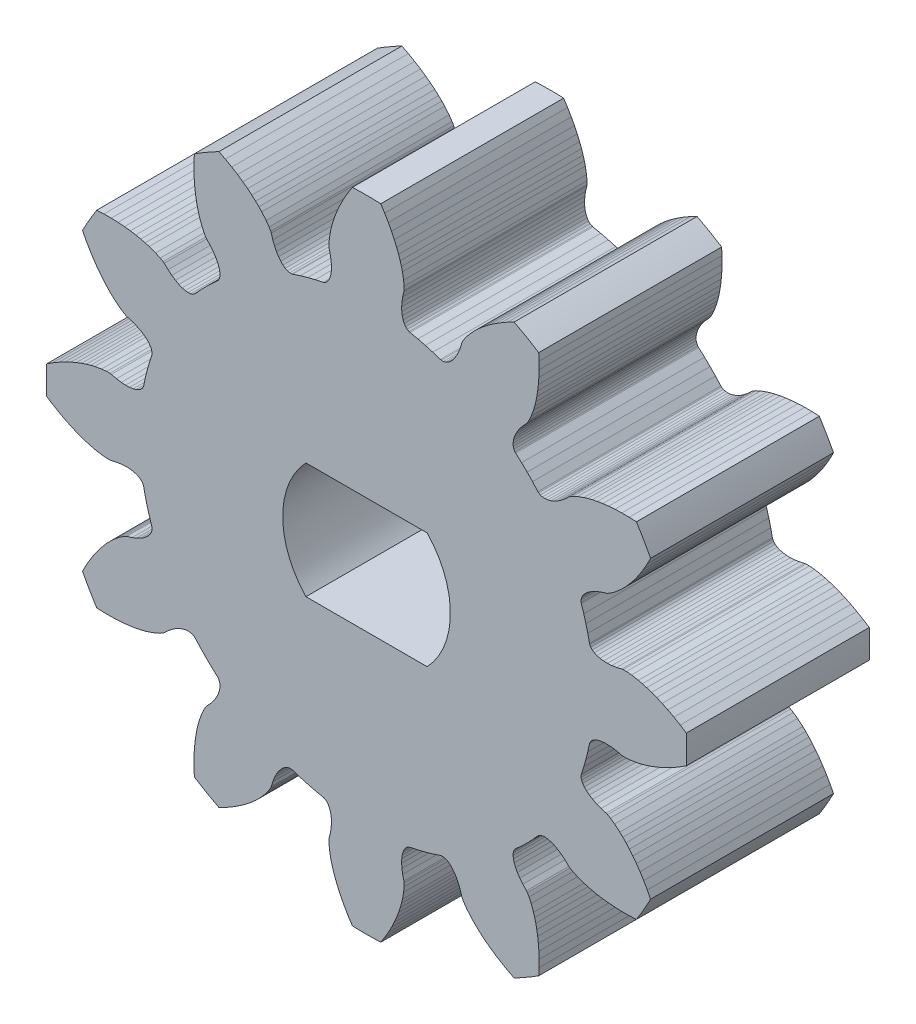
from build123d import *

# Parameters (mm, degrees)
BOSS_EXTRUDE1_DEPTH     = 3
CUT_EXTRUDE1_DEPTH      = 1
CUT_EXTRUDE1_DEPTH_BACK = 7


with BuildPart() as part:
    # Model → Boss-Extrude1 (new body, symmetric)
    with BuildSketch(Plane.XY):
        with BuildLine():
            Line((9.2081638, 4.6306746), (9.0896937, 4.4223953))
            Line((9.0896937, 4.4223953), (8.9704789, 4.2318475))
            Line((8.9704789, 4.2318475), (8.8518121, 4.0587667))
            Line((8.8518121, 4.0587667), (8.7350822, 3.9029142))
            Line((8.7350822, 3.9029142), (8.6215838, 3.7639019))
            Line((8.6215838, 3.7639019), (8.510786, 3.6392686))
            Line((8.510786, 3.6392686), (8.4071579, 3.5321165))
            Line((8.4071579, 3.5321165), (8.3089199, 3.4386561))
            Line((8.3089199, 3.4386561), (8.1362464, 3.2934574))
            Line((8.1362464, 3.2934574), (7.9993186, 3.196525))
            Line((7.9993186, 3.196525), (7.9059174, 3.1414234))
            Line((7.9059174, 3.1414234), (7.8611648, 3.1240278))
            Line((7.8611648, 3.1240278), (7.69584, 3.074501))
            Line((7.69584, 3.074501), (7.5485028, 3.0172672))
            Line((7.5485028, 3.0172672), (7.4194762, 2.9537483))
            Line((7.4194762, 2.9537483), (7.3090078, 2.8853773))
            Line((7.3090078, 2.8853773), (7.2172479, 2.8136024))
            Line((7.2172479, 2.8136024), (7.1442598, 2.7398486))
            Line((7.1442598, 2.7398486), (7.0900211, 2.6655903))
            Line((7.0900211, 2.6655903), (7.0544136, 2.5922348))
            Line((7.0544136, 2.5922348), (7.037248, 2.5212224))
            Line((7.037248, 2.5212224), (7.0382291, 2.4539645))
            Line((7.0382291, 2.4539645), (7.0454224, 2.4221731))
            Line((7.0454224, 2.4221731), (7.126272, 2.1723665))
            Line((7.126272, 2.1723665), (7.1961474, 1.9282019))
            Line((7.1961474, 1.9282019), (7.2577158, 1.6818114))
            Line((7.2577158, 1.6818114), (7.3126013, 1.4250478))
            Line((7.3126013, 1.4250478), (7.3222675, 1.3939189))
            Line((7.3222675, 1.3939189), (7.3550468, 1.3351814))
            Line((7.3550468, 1.3351814), (7.4054188, 1.2822656))
            Line((7.4054188, 1.2822656), (7.4729335, 1.2365416))
            Line((7.4729335, 1.2365416), (7.5570347, 1.1993514))
            Line((7.5570347, 1.1993514), (7.6571212, 1.1719728))
            Line((7.6571212, 1.1719728), (7.7724751, 1.1556939))
            Line((7.7724751, 1.1556939), (7.902329, 1.1517171))
            Line((7.902329, 1.1517171), (8.0458288, 1.1612214))
            Line((8.0458288, 1.1612214), (8.2020434, 1.185324))
            Line((8.2020434, 1.185324), (8.3699823, 1.2250949))
            Line((8.3699823, 1.2250949), (8.417437, 1.2324062))
            Line((8.417437, 1.2324062), (8.5258756, 1.2313875))
            Line((8.5258756, 1.2313875), (8.6929247, 1.2159055))
            Line((8.6929247, 1.2159055), (8.9150637, 1.1764964))
            Line((8.9150637, 1.1764964), (9.0468706, 1.1446763))
            Line((9.0468706, 1.1446763), (9.1901912, 1.103694))
            Line((9.1901912, 1.103694), (9.3484616, 1.0511572))
            Line((9.3484616, 1.0511572), (9.5162602, 0.9875182))
            Line((9.5162602, 0.9875182), (9.6952775, 0.910911))
            Line((9.6952775, 0.910911), (9.8845864, 0.820352))
            Line((9.8845864, 0.820352), (10.0831033, 0.7149402))
            Line((10.0831033, 0.7149402), (10.2898411, 0.5938001))
            Line((10.2898411, 0.5938001), (10.489639, 0.465274))
            ThreePointArc((10.489639, 0.465274), (10.499952632, 0), (10.489639, -0.465274))
            Line((10.489639, -0.465274), (10.2898411, -0.5938001))
            Line((10.2898411, -0.5938001), (10.0831033, -0.7149402))
            Line((10.0831033, -0.7149402), (9.8845864, -0.820352))
            Line((9.8845864, -0.820352), (9.6952775, -0.910911))
            Line((9.6952775, -0.910911), (9.5162602, -0.9875182))
            Line((9.5162602, -0.9875182), (9.3484616, -1.0511572))
            Line((9.3484616, -1.0511572), (9.1901912, -1.103694))
            Line((9.1901912, -1.103694), (9.0468706, -1.1446763))
            Line((9.0468706, -1.1446763), (8.9150637, -1.1764964))
            Line((8.9150637, -1.1764964), (8.6929247, -1.2159055))
            Line((8.6929247, -1.2159055), (8.5258756, -1.2313875))
            Line((8.5258756, -1.2313875), (8.417437, -1.2324062))
            Line((8.417437, -1.2324062), (8.3699823, -1.2250949))
            Line((8.3699823, -1.2250949), (8.2020434, -1.185324))
            Line((8.2020434, -1.185324), (8.0458288, -1.1612214))
            Line((8.0458288, -1.1612214), (7.902329, -1.1517171))
            Line((7.902329, -1.1517171), (7.7724751, -1.1556939))
            Line((7.7724751, -1.1556939), (7.6571212, -1.1719728))
            Line((7.6571212, -1.1719728), (7.5570347, -1.1993514))
            Line((7.5570347, -1.1993514), (7.4729335, -1.2365416))
            Line((7.4729335, -1.2365416), (7.4054188, -1.2822656))
            Line((7.4054188, -1.2822656), (7.3550468, -1.3351814))
            Line((7.3550468, -1.3351814), (7.3222675, -1.3939189))
            Line((7.3222675, -1.3939189), (7.3126013, -1.4250478))
            Line((7.3126013, -1.4250478), (7.2577158, -1.6818114))
            Line((7.2577158, -1.6818114), (7.1961474, -1.9282019))
            Line((7.1961474, -1.9282019), (7.126272, -2.1723665))
            Line((7.126272, -2.1723665), (7.0454224, -2.4221731))
            Line((7.0454224, -2.4221731), (7.0382291, -2.4539645))
            Line((7.0382291, -2.4539645), (7.037248, -2.5212224))
            Line((7.037248, -2.5212224), (7.0544136, -2.5922348))
            Line((7.0544136, -2.5922348), (7.0900211, -2.6655903))
            Line((7.0900211, -2.6655903), (7.1442598, -2.7398486))
            Line((7.1442598, -2.7398486), (7.2172479, -2.8136024))
            Line((7.2172479, -2.8136024), (7.3090078, -2.8853773))
            Line((7.3090078, -2.8853773), (7.4194762, -2.9537483))
            Line((7.4194762, -2.9537483), (7.5485028, -3.0172672))
            Line((7.5485028, -3.0172672), (7.69584, -3.074501))
            Line((7.69584, -3.074501), (7.8611648, -3.1240278))
            Line((7.8611648, -3.1240278), (7.9059174, -3.1414234))
            Line((7.9059174, -3.1414234), (7.9993186, -3.196525))
            Line((7.9993186, -3.196525), (8.1362464, -3.2934574))
            Line((8.1362464, -3.2934574), (8.3089199, -3.4386561))
            Line((8.3089199, -3.4386561), (8.4071579, -3.5321165))
            Line((8.4071579, -3.5321165), (8.510786, -3.6392686))
            Line((8.510786, -3.6392686), (8.6215838, -3.7639019))
            Line((8.6215838, -3.7639019), (8.7350822, -3.9029142))
            Line((8.7350822, -3.9029142), (8.8518121, -4.0587667))
            Line((8.8518121, -4.0587667), (8.9704789, -4.2318475))
            Line((8.9704789, -4.2318475), (9.0896937, -4.4223953))
            Line((9.0896937, -4.4223953), (9.2081638, -4.6306746))
            Line((9.2081638, -4.6306746), (9.3169308, -4.8418803))
            ThreePointArc((9.3169308, -4.8418803), (9.093225669, -5.249976266), (8.8516568, -5.6477586))
            Line((8.8516568, -5.6477586), (8.6143637, -5.6591665))
            Line((8.6143637, -5.6591665), (8.3747535, -5.660708))
            Line((8.3747535, -5.660708), (8.1501269, -5.6527389))
            Line((8.1501269, -5.6527389), (7.9409011, -5.6365108))
            Line((7.9409011, -5.6365108), (7.7475639, -5.613346))
            Line((7.7475639, -5.613346), (7.5704266, -5.5845597))
            Line((7.5704266, -5.5845597), (7.407092, -5.5509226))
            Line((7.407092, -5.5509226), (7.2624816, -5.5147541))
            Line((7.2624816, -5.5147541), (7.1324235, -5.4764077))
            Line((7.1324235, -5.4764077), (6.9203409, -5.3994674))
            Line((6.9203409, -5.3994674), (6.7679311, -5.3293507))
            Line((6.7679311, -5.3293507), (6.6735112, -5.2760136))
            Line((6.6735112, -5.2760136), (6.6360699, -5.2459545))
            Line((6.6360699, -5.2459545), (6.510516, -5.1275424))
            Line((6.510516, -5.1275424), (6.3872814, -5.0285616))
            Line((6.3872814, -5.0285616), (6.2677592, -4.9485807))
            Line((6.2677592, -4.9485807), (6.1533139, -4.8870978))
            Line((6.1533139, -4.8870978), (6.0452751, -4.8435188))
            Line((6.0452751, -4.8435188), (5.9449083, -4.8171862))
            Line((5.9449083, -4.8171862), (5.8534794, -4.8073432))
            Line((5.8534794, -4.8073432), (5.772148, -4.8131839))
            Line((5.772148, -4.8131839), (5.7020667, -4.8338244))
            Line((5.7020667, -4.8338244), (5.6443102, -4.8683029))
            Line((5.6443102, -4.8683029), (5.6203746, -4.8904283))
            Line((5.6203746, -4.8904283), (5.4444606, -5.0853493))
            Line((5.4444606, -5.0853493), (5.2679455, -5.2679455))
            Line((5.2679455, -5.2679455), (5.0853493, -5.4444606))
            Line((5.0853493, -5.4444606), (4.8904283, -5.6203746))
            Line((4.8904283, -5.6203746), (4.8683029, -5.6443102))
            Line((4.8683029, -5.6443102), (4.8338244, -5.7020667))
            Line((4.8338244, -5.7020667), (4.8131839, -5.772148))
            Line((4.8131839, -5.772148), (4.8073432, -5.8534794))
            Line((4.8073432, -5.8534794), (4.8171862, -5.9449083))
            Line((4.8171862, -5.9449083), (4.8435188, -6.0452751))
            Line((4.8435188, -6.0452751), (4.8870978, -6.1533139))
            Line((4.8870978, -6.1533139), (4.9485807, -6.2677592))
            Line((4.9485807, -6.2677592), (5.0285616, -6.3872814))
            Line((5.0285616, -6.3872814), (5.1275424, -6.510516))
            Line((5.1275424, -6.510516), (5.2459545, -6.6360699))
            Line((5.2459545, -6.6360699), (5.2760136, -6.6735112))
            Line((5.2760136, -6.6735112), (5.3293507, -6.7679311))
            Line((5.3293507, -6.7679311), (5.3994674, -6.9203409))
            Line((5.3994674, -6.9203409), (5.4764077, -7.1324235))
            Line((5.4764077, -7.1324235), (5.5147541, -7.2624816))
            Line((5.5147541, -7.2624816), (5.5509226, -7.407092))
            Line((5.5509226, -7.407092), (5.5845597, -7.5704266))
            Line((5.5845597, -7.5704266), (5.613346, -7.7475639))
            Line((5.613346, -7.7475639), (5.6365108, -7.9409011))
            Line((5.6365108, -7.9409011), (5.6527389, -8.1501269))
            Line((5.6527389, -8.1501269), (5.660708, -8.3747535))
            Line((5.660708, -8.3747535), (5.6591665, -8.6143637))
            Line((5.6591665, -8.6143637), (5.6477586, -8.8516568))
            ThreePointArc((5.6477586, -8.8516568), (5.249976266, -9.093225669), (4.8418803, -9.3169308))
            Line((4.8418803, -9.3169308), (4.6306746, -9.2081638))
            Line((4.6306746, -9.2081638), (4.4223953, -9.0896937))
            Line((4.4223953, -9.0896937), (4.2318475, -8.9704789))
            Line((4.2318475, -8.9704789), (4.0587667, -8.8518121))
            Line((4.0587667, -8.8518121), (3.9029142, -8.7350822))
            Line((3.9029142, -8.7350822), (3.7639019, -8.6215838))
            Line((3.7639019, -8.6215838), (3.6392686, -8.510786))
            Line((3.6392686, -8.510786), (3.5321165, -8.4071579))
            Line((3.5321165, -8.4071579), (3.4386561, -8.3089199))
            Line((3.4386561, -8.3089199), (3.2934574, -8.1362464))
            Line((3.2934574, -8.1362464), (3.196525, -7.9993186))
            Line((3.196525, -7.9993186), (3.1414234, -7.9059174))
            Line((3.1414234, -7.9059174), (3.1240278, -7.8611648))
            Line((3.1240278, -7.8611648), (3.074501, -7.69584))
            Line((3.074501, -7.69584), (3.0172672, -7.5485028))
            Line((3.0172672, -7.5485028), (2.9537483, -7.4194762))
            Line((2.9537483, -7.4194762), (2.8853773, -7.3090078))
            Line((2.8853773, -7.3090078), (2.8136024, -7.2172479))
            Line((2.8136024, -7.2172479), (2.7398486, -7.1442598))
            Line((2.7398486, -7.1442598), (2.6655903, -7.0900211))
            Line((2.6655903, -7.0900211), (2.5922348, -7.0544136))
            Line((2.5922348, -7.0544136), (2.5212224, -7.037248))
            Line((2.5212224, -7.037248), (2.4539645, -7.0382291))
            Line((2.4539645, -7.0382291), (2.4221731, -7.0454224))
            Line((2.4221731, -7.0454224), (2.1723665, -7.126272))
            Line((2.1723665, -7.126272), (1.9282019, -7.1961474))
            Line((1.9282019, -7.1961474), (1.6818114, -7.2577158))
            Line((1.6818114, -7.2577158), (1.4250478, -7.3126013))
            Line((1.4250478, -7.3126013), (1.3939189, -7.3222675))
            Line((1.3939189, -7.3222675), (1.3351814, -7.3550468))
            Line((1.3351814, -7.3550468), (1.2822656, -7.4054188))
            Line((1.2822656, -7.4054188), (1.2365416, -7.4729335))
            Line((1.2365416, -7.4729335), (1.1993514, -7.5570347))
            Line((1.1993514, -7.5570347), (1.1719728, -7.6571212))
            Line((1.1719728, -7.6571212), (1.1556939, -7.7724751))
            Line((1.1556939, -7.7724751), (1.1517171, -7.902329))
            Line((1.1517171, -7.902329), (1.1612214, -8.0458288))
            Line((1.1612214, -8.0458288), (1.185324, -8.2020434))
            Line((1.185324, -8.2020434), (1.2250949, -8.3699823))
            Line((1.2250949, -8.3699823), (1.2324062, -8.417437))
            Line((1.2324062, -8.417437), (1.2313875, -8.5258756))
            Line((1.2313875, -8.5258756), (1.2159055, -8.6929247))
            Line((1.2159055, -8.6929247), (1.1764964, -8.9150637))
            Line((1.1764964, -8.9150637), (1.1446763, -9.0468706))
            Line((1.1446763, -9.0468706), (1.103694, -9.1901912))
            Line((1.103694, -9.1901912), (1.0511572, -9.3484616))
            Line((1.0511572, -9.3484616), (0.9875182, -9.5162602))
            Line((0.9875182, -9.5162602), (0.910911, -9.6952775))
            Line((0.910911, -9.6952775), (0.820352, -9.8845864))
            Line((0.820352, -9.8845864), (0.7149402, -10.0831033))
            Line((0.7149402, -10.0831033), (0.5938001, -10.2898411))
            Line((0.5938001, -10.2898411), (0.465274, -10.489639))
            ThreePointArc((0.465274, -10.489639), (0, -10.499952632), (-0.465274, -10.489639))
            Line((-0.465274, -10.489639), (-0.5938001, -10.2898411))
            Line((-0.5938001, -10.2898411), (-0.7149402, -10.0831033))
            Line((-0.7149402, -10.0831033), (-0.820352, -9.8845864))
            Line((-0.820352, -9.8845864), (-0.910911, -9.6952775))
            Line((-0.910911, -9.6952775), (-0.9875182, -9.5162602))
            Line((-0.9875182, -9.5162602), (-1.0511572, -9.3484616))
            Line((-1.0511572, -9.3484616), (-1.103694, -9.1901912))
            Line((-1.103694, -9.1901912), (-1.1446763, -9.0468706))
            Line((-1.1446763, -9.0468706), (-1.1764964, -8.9150637))
            Line((-1.1764964, -8.9150637), (-1.2159055, -8.6929247))
            Line((-1.2159055, -8.6929247), (-1.2313875, -8.5258756))
            Line((-1.2313875, -8.5258756), (-1.2324062, -8.417437))
            Line((-1.2324062, -8.417437), (-1.2250949, -8.3699823))
            Line((-1.2250949, -8.3699823), (-1.185324, -8.2020434))
            Line((-1.185324, -8.2020434), (-1.1612214, -8.0458288))
            Line((-1.1612214, -8.0458288), (-1.1517171, -7.902329))
            Line((-1.1517171, -7.902329), (-1.1556939, -7.7724751))
            Line((-1.1556939, -7.7724751), (-1.1719728, -7.6571212))
            Line((-1.1719728, -7.6571212), (-1.1993514, -7.5570347))
            Line((-1.1993514, -7.5570347), (-1.2365416, -7.4729335))
            Line((-1.2365416, -7.4729335), (-1.2822656, -7.4054188))
            Line((-1.2822656, -7.4054188), (-1.3351814, -7.3550468))
            Line((-1.3351814, -7.3550468), (-1.3939189, -7.3222675))
            Line((-1.3939189, -7.3222675), (-1.4250478, -7.3126013))
            Line((-1.4250478, -7.3126013), (-1.6818114, -7.2577158))
            Line((-1.6818114, -7.2577158), (-1.9282019, -7.1961474))
            Line((-1.9282019, -7.1961474), (-2.1723665, -7.126272))
            Line((-2.1723665, -7.126272), (-2.4221731, -7.0454224))
            Line((-2.4221731, -7.0454224), (-2.4539645, -7.0382291))
            Line((-2.4539645, -7.0382291), (-2.5212224, -7.037248))
            Line((-2.5212224, -7.037248), (-2.5922348, -7.0544136))
            Line((-2.5922348, -7.0544136), (-2.6655903, -7.0900211))
            Line((-2.6655903, -7.0900211), (-2.7398486, -7.1442598))
            Line((-2.7398486, -7.1442598), (-2.8136024, -7.2172479))
            Line((-2.8136024, -7.2172479), (-2.8853773, -7.3090078))
            Line((-2.8853773, -7.3090078), (-2.9537483, -7.4194762))
            Line((-2.9537483, -7.4194762), (-3.0172672, -7.5485028))
            Line((-3.0172672, -7.5485028), (-3.074501, -7.69584))
            Line((-3.074501, -7.69584), (-3.1240278, -7.8611648))
            Line((-3.1240278, -7.8611648), (-3.1414234, -7.9059174))
            Line((-3.1414234, -7.9059174), (-3.196525, -7.9993186))
            Line((-3.196525, -7.9993186), (-3.2934574, -8.1362464))
            Line((-3.2934574, -8.1362464), (-3.4386561, -8.3089199))
            Line((-3.4386561, -8.3089199), (-3.5321165, -8.4071579))
            Line((-3.5321165, -8.4071579), (-3.6392686, -8.510786))
            Line((-3.6392686, -8.510786), (-3.7639019, -8.6215838))
            Line((-3.7639019, -8.6215838), (-3.9029142, -8.7350822))
            Line((-3.9029142, -8.7350822), (-4.0587667, -8.8518121))
            Line((-4.0587667, -8.8518121), (-4.2318475, -8.9704789))
            Line((-4.2318475, -8.9704789), (-4.4223953, -9.0896937))
            Line((-4.4223953, -9.0896937), (-4.6306746, -9.2081638))
            Line((-4.6306746, -9.2081638), (-4.8418803, -9.3169308))
            ThreePointArc((-4.8418803, -9.3169308), (-5.249976266, -9.093225669), (-5.6477586, -8.8516568))
            Line((-5.6477586, -8.8516568), (-5.6591665, -8.6143637))
            Line((-5.6591665, -8.6143637), (-5.660708, -8.3747535))
            Line((-5.660708, -8.3747535), (-5.6527389, -8.1501269))
            Line((-5.6527389, -8.1501269), (-5.6365108, -7.9409011))
            Line((-5.6365108, -7.9409011), (-5.613346, -7.7475639))
            Line((-5.613346, -7.7475639), (-5.5845597, -7.5704266))
            Line((-5.5845597, -7.5704266), (-5.5509226, -7.407092))
            Line((-5.5509226, -7.407092), (-5.5147541, -7.2624816))
            Line((-5.5147541, -7.2624816), (-5.4764077, -7.1324235))
            Line((-5.4764077, -7.1324235), (-5.3994674, -6.9203409))
            Line((-5.3994674, -6.9203409), (-5.3293507, -6.7679311))
            Line((-5.3293507, -6.7679311), (-5.2760136, -6.6735112))
            Line((-5.2760136, -6.6735112), (-5.2459545, -6.6360699))
            Line((-5.2459545, -6.6360699), (-5.1275424, -6.510516))
            Line((-5.1275424, -6.510516), (-5.0285616, -6.3872814))
            Line((-5.0285616, -6.3872814), (-4.9485807, -6.2677592))
            Line((-4.9485807, -6.2677592), (-4.8870978, -6.1533139))
            Line((-4.8870978, -6.1533139), (-4.8435188, -6.0452751))
            Line((-4.8435188, -6.0452751), (-4.8171862, -5.9449083))
            Line((-4.8171862, -5.9449083), (-4.8073432, -5.8534794))
            Line((-4.8073432, -5.8534794), (-4.8131839, -5.772148))
            Line((-4.8131839, -5.772148), (-4.8338244, -5.7020667))
            Line((-4.8338244, -5.7020667), (-4.8683029, -5.6443102))
            Line((-4.8683029, -5.6443102), (-4.8904283, -5.6203746))
            Line((-4.8904283, -5.6203746), (-5.0853493, -5.4444606))
            Line((-5.0853493, -5.4444606), (-5.2679455, -5.2679455))
            Line((-5.2679455, -5.2679455), (-5.4444606, -5.0853493))
            Line((-5.4444606, -5.0853493), (-5.6203746, -4.8904283))
            Line((-5.6203746, -4.8904283), (-5.6443102, -4.8683029))
            Line((-5.6443102, -4.8683029), (-5.7020667, -4.8338244))
            Line((-5.7020667, -4.8338244), (-5.772148, -4.8131839))
            Line((-5.772148, -4.8131839), (-5.8534794, -4.8073432))
            Line((-5.8534794, -4.8073432), (-5.9449083, -4.8171862))
            Line((-5.9449083, -4.8171862), (-6.0452751, -4.8435188))
            Line((-6.0452751, -4.8435188), (-6.1533139, -4.8870978))
            Line((-6.1533139, -4.8870978), (-6.2677592, -4.9485807))
            Line((-6.2677592, -4.9485807), (-6.3872814, -5.0285616))
            Line((-6.3872814, -5.0285616), (-6.510516, -5.1275424))
            Line((-6.510516, -5.1275424), (-6.6360699, -5.2459545))
            Line((-6.6360699, -5.2459545), (-6.6735112, -5.2760136))
            Line((-6.6735112, -5.2760136), (-6.7679311, -5.3293507))
            Line((-6.7679311, -5.3293507), (-6.9203409, -5.3994674))
            Line((-6.9203409, -5.3994674), (-7.1324235, -5.4764077))
            Line((-7.1324235, -5.4764077), (-7.2624816, -5.5147541))
            Line((-7.2624816, -5.5147541), (-7.407092, -5.5509226))
            Line((-7.407092, -5.5509226), (-7.5704266, -5.5845597))
            Line((-7.5704266, -5.5845597), (-7.7475639, -5.613346))
            Line((-7.7475639, -5.613346), (-7.9409011, -5.6365108))
            Line((-7.9409011, -5.6365108), (-8.1501269, -5.6527389))
            Line((-8.1501269, -5.6527389), (-8.3747535, -5.660708))
            Line((-8.3747535, -5.660708), (-8.6143637, -5.6591665))
            Line((-8.6143637, -5.6591665), (-8.8516568, -5.6477586))
            ThreePointArc((-8.8516568, -5.6477586), (-9.093225669, -5.249976266), (-9.3169308, -4.8418803))
            Line((-9.3169308, -4.8418803), (-9.2081638, -4.6306746))
            Line((-9.2081638, -4.6306746), (-9.0896937, -4.4223953))
            Line((-9.0896937, -4.4223953), (-8.9704789, -4.2318475))
            Line((-8.9704789, -4.2318475), (-8.8518121, -4.0587667))
            Line((-8.8518121, -4.0587667), (-8.7350822, -3.9029142))
            Line((-8.7350822, -3.9029142), (-8.6215838, -3.7639019))
            Line((-8.6215838, -3.7639019), (-8.510786, -3.6392686))
            Line((-8.510786, -3.6392686), (-8.4071579, -3.5321165))
            Line((-8.4071579, -3.5321165), (-8.3089199, -3.4386561))
            Line((-8.3089199, -3.4386561), (-8.1362464, -3.2934574))
            Line((-8.1362464, -3.2934574), (-7.9993186, -3.196525))
            Line((-7.9993186, -3.196525), (-7.9059174, -3.1414234))
            Line((-7.9059174, -3.1414234), (-7.8611648, -3.1240278))
            Line((-7.8611648, -3.1240278), (-7.69584, -3.074501))
            Line((-7.69584, -3.074501), (-7.5485028, -3.0172672))
            Line((-7.5485028, -3.0172672), (-7.4194762, -2.9537483))
            Line((-7.4194762, -2.9537483), (-7.3090078, -2.8853773))
            Line((-7.3090078, -2.8853773), (-7.2172479, -2.8136024))
            Line((-7.2172479, -2.8136024), (-7.1442598, -2.7398486))
            Line((-7.1442598, -2.7398486), (-7.0900211, -2.6655903))
            Line((-7.0900211, -2.6655903), (-7.0544136, -2.5922348))
            Line((-7.0544136, -2.5922348), (-7.037248, -2.5212224))
            Line((-7.037248, -2.5212224), (-7.0382291, -2.4539645))
            Line((-7.0382291, -2.4539645), (-7.0454224, -2.4221731))
            Line((-7.0454224, -2.4221731), (-7.126272, -2.1723665))
            Line((-7.126272, -2.1723665), (-7.1961474, -1.9282019))
            Line((-7.1961474, -1.9282019), (-7.2577158, -1.6818114))
            Line((-7.2577158, -1.6818114), (-7.3126013, -1.4250478))
            Line((-7.3126013, -1.4250478), (-7.3222675, -1.3939189))
            Line((-7.3222675, -1.3939189), (-7.3550468, -1.3351814))
            Line((-7.3550468, -1.3351814), (-7.4054188, -1.2822656))
            Line((-7.4054188, -1.2822656), (-7.4729335, -1.2365416))
            Line((-7.4729335, -1.2365416), (-7.5570347, -1.1993514))
            Line((-7.5570347, -1.1993514), (-7.6571212, -1.1719728))
            Line((-7.6571212, -1.1719728), (-7.7724751, -1.1556939))
            Line((-7.7724751, -1.1556939), (-7.902329, -1.1517171))
            Line((-7.902329, -1.1517171), (-8.0458288, -1.1612214))
            Line((-8.0458288, -1.1612214), (-8.2020434, -1.185324))
            Line((-8.2020434, -1.185324), (-8.3699823, -1.2250949))
            Line((-8.3699823, -1.2250949), (-8.417437, -1.2324062))
            Line((-8.417437, -1.2324062), (-8.5258756, -1.2313875))
            Line((-8.5258756, -1.2313875), (-8.6929247, -1.2159055))
            Line((-8.6929247, -1.2159055), (-8.9150637, -1.1764964))
            Line((-8.9150637, -1.1764964), (-9.0468706, -1.1446763))
            Line((-9.0468706, -1.1446763), (-9.1901912, -1.103694))
            Line((-9.1901912, -1.103694), (-9.3484616, -1.0511572))
            Line((-9.3484616, -1.0511572), (-9.5162602, -0.9875182))
            Line((-9.5162602, -0.9875182), (-9.6952775, -0.910911))
            Line((-9.6952775, -0.910911), (-9.8845864, -0.820352))
            Line((-9.8845864, -0.820352), (-10.0831033, -0.7149402))
            Line((-10.0831033, -0.7149402), (-10.2898411, -0.5938001))
            Line((-10.2898411, -0.5938001), (-10.489639, -0.465274))
            ThreePointArc((-10.489639, -0.465274), (-10.499952632, 0), (-10.489639, 0.465274))
            Line((-10.489639, 0.465274), (-10.2898411, 0.5938001))
            Line((-10.2898411, 0.5938001), (-10.0831033, 0.7149402))
            Line((-10.0831033, 0.7149402), (-9.8845864, 0.820352))
            Line((-9.8845864, 0.820352), (-9.6952775, 0.910911))
            Line((-9.6952775, 0.910911), (-9.5162602, 0.9875182))
            Line((-9.5162602, 0.9875182), (-9.3484616, 1.0511572))
            Line((-9.3484616, 1.0511572), (-9.1901912, 1.103694))
            Line((-9.1901912, 1.103694), (-9.0468706, 1.1446763))
            Line((-9.0468706, 1.1446763), (-8.9150637, 1.1764964))
            Line((-8.9150637, 1.1764964), (-8.6929247, 1.2159055))
            Line((-8.6929247, 1.2159055), (-8.5258756, 1.2313875))
            Line((-8.5258756, 1.2313875), (-8.417437, 1.2324062))
            Line((-8.417437, 1.2324062), (-8.3699823, 1.2250949))
            Line((-8.3699823, 1.2250949), (-8.2020434, 1.185324))
            Line((-8.2020434, 1.185324), (-8.0458288, 1.1612214))
            Line((-8.0458288, 1.1612214), (-7.902329, 1.1517171))
            Line((-7.902329, 1.1517171), (-7.7724751, 1.1556939))
            Line((-7.7724751, 1.1556939), (-7.6571212, 1.1719728))
            Line((-7.6571212, 1.1719728), (-7.5570347, 1.1993514))
            Line((-7.5570347, 1.1993514), (-7.4729335, 1.2365416))
            Line((-7.4729335, 1.2365416), (-7.4054188, 1.2822656))
            Line((-7.4054188, 1.2822656), (-7.3550468, 1.3351814))
            Line((-7.3550468, 1.3351814), (-7.3222675, 1.3939189))
            Line((-7.3222675, 1.3939189), (-7.3126013, 1.4250478))
            Line((-7.3126013, 1.4250478), (-7.2577158, 1.6818114))
            Line((-7.2577158, 1.6818114), (-7.1961474, 1.9282019))
            Line((-7.1961474, 1.9282019), (-7.126272, 2.1723665))
            Line((-7.126272, 2.1723665), (-7.0454224, 2.4221731))
            Line((-7.0454224, 2.4221731), (-7.0382291, 2.4539645))
            Line((-7.0382291, 2.4539645), (-7.037248, 2.5212224))
            Line((-7.037248, 2.5212224), (-7.0544136, 2.5922348))
            Line((-7.0544136, 2.5922348), (-7.0900211, 2.6655903))
            Line((-7.0900211, 2.6655903), (-7.1442598, 2.7398486))
            Line((-7.1442598, 2.7398486), (-7.2172479, 2.8136024))
            Line((-7.2172479, 2.8136024), (-7.3090078, 2.8853773))
            Line((-7.3090078, 2.8853773), (-7.4194762, 2.9537483))
            Line((-7.4194762, 2.9537483), (-7.5485028, 3.0172672))
            Line((-7.5485028, 3.0172672), (-7.69584, 3.074501))
            Line((-7.69584, 3.074501), (-7.8611648, 3.1240278))
            Line((-7.8611648, 3.1240278), (-7.9059174, 3.1414234))
            Line((-7.9059174, 3.1414234), (-7.9993186, 3.196525))
            Line((-7.9993186, 3.196525), (-8.1362464, 3.2934574))
            Line((-8.1362464, 3.2934574), (-8.3089199, 3.4386561))
            Line((-8.3089199, 3.4386561), (-8.4071579, 3.5321165))
            Line((-8.4071579, 3.5321165), (-8.510786, 3.6392686))
            Line((-8.510786, 3.6392686), (-8.6215838, 3.7639019))
            Line((-8.6215838, 3.7639019), (-8.7350822, 3.9029142))
            Line((-8.7350822, 3.9029142), (-8.8518121, 4.0587667))
            Line((-8.8518121, 4.0587667), (-8.9704789, 4.2318475))
            Line((-8.9704789, 4.2318475), (-9.0896937, 4.4223953))
            Line((-9.0896937, 4.4223953), (-9.2081638, 4.6306746))
            Line((-9.2081638, 4.6306746), (-9.3169308, 4.8418803))
            ThreePointArc((-9.3169308, 4.8418803), (-9.093225669, 5.249976266), (-8.8516568, 5.6477586))
            Line((-8.8516568, 5.6477586), (-8.6143637, 5.6591665))
            Line((-8.6143637, 5.6591665), (-8.3747535, 5.660708))
            Line((-8.3747535, 5.660708), (-8.1501269, 5.6527389))
            Line((-8.1501269, 5.6527389), (-7.9409011, 5.6365108))
            Line((-7.9409011, 5.6365108), (-7.7475639, 5.613346))
            Line((-7.7475639, 5.613346), (-7.5704266, 5.5845597))
            Line((-7.5704266, 5.5845597), (-7.407092, 5.5509226))
            Line((-7.407092, 5.5509226), (-7.2624816, 5.5147541))
            Line((-7.2624816, 5.5147541), (-7.1324235, 5.4764077))
            Line((-7.1324235, 5.4764077), (-6.9203409, 5.3994674))
            Line((-6.9203409, 5.3994674), (-6.7679311, 5.3293507))
            Line((-6.7679311, 5.3293507), (-6.6735112, 5.2760136))
            Line((-6.6735112, 5.2760136), (-6.6360699, 5.2459545))
            Line((-6.6360699, 5.2459545), (-6.510516, 5.1275424))
            Line((-6.510516, 5.1275424), (-6.3872814, 5.0285616))
            Line((-6.3872814, 5.0285616), (-6.2677592, 4.9485807))
            Line((-6.2677592, 4.9485807), (-6.1533139, 4.8870978))
            Line((-6.1533139, 4.8870978), (-6.0452751, 4.8435188))
            Line((-6.0452751, 4.8435188), (-5.9449083, 4.8171862))
            Line((-5.9449083, 4.8171862), (-5.8534794, 4.8073432))
            Line((-5.8534794, 4.8073432), (-5.772148, 4.8131839))
            Line((-5.772148, 4.8131839), (-5.7020667, 4.8338244))
            Line((-5.7020667, 4.8338244), (-5.6443102, 4.8683029))
            Line((-5.6443102, 4.8683029), (-5.6203746, 4.8904283))
            Line((-5.6203746, 4.8904283), (-5.4444606, 5.0853493))
            Line((-5.4444606, 5.0853493), (-5.2679455, 5.2679455))
            Line((-5.2679455, 5.2679455), (-5.0853493, 5.4444606))
            Line((-5.0853493, 5.4444606), (-4.8904283, 5.6203746))
            Line((-4.8904283, 5.6203746), (-4.8683029, 5.6443102))
            Line((-4.8683029, 5.6443102), (-4.8338244, 5.7020667))
            Line((-4.8338244, 5.7020667), (-4.8131839, 5.772148))
            Line((-4.8131839, 5.772148), (-4.8073432, 5.8534794))
            Line((-4.8073432, 5.8534794), (-4.8171862, 5.9449083))
            Line((-4.8171862, 5.9449083), (-4.8435188, 6.0452751))
            Line((-4.8435188, 6.0452751), (-4.8870978, 6.1533139))
            Line((-4.8870978, 6.1533139), (-4.9485807, 6.2677592))
            Line((-4.9485807, 6.2677592), (-5.0285616, 6.3872814))
            Line((-5.0285616, 6.3872814), (-5.1275424, 6.510516))
            Line((-5.1275424, 6.510516), (-5.2459545, 6.6360699))
            Line((-5.2459545, 6.6360699), (-5.2760136, 6.6735112))
            Line((-5.2760136, 6.6735112), (-5.3293507, 6.7679311))
            Line((-5.3293507, 6.7679311), (-5.3994674, 6.9203409))
            Line((-5.3994674, 6.9203409), (-5.4764077, 7.1324235))
            Line((-5.4764077, 7.1324235), (-5.5147541, 7.2624816))
            Line((-5.5147541, 7.2624816), (-5.5509226, 7.407092))
            Line((-5.5509226, 7.407092), (-5.5845597, 7.5704266))
            Line((-5.5845597, 7.5704266), (-5.613346, 7.7475639))
            Line((-5.613346, 7.7475639), (-5.6365108, 7.9409011))
            Line((-5.6365108, 7.9409011), (-5.6527389, 8.1501269))
            Line((-5.6527389, 8.1501269), (-5.660708, 8.3747535))
            Line((-5.660708, 8.3747535), (-5.6591665, 8.6143637))
            Line((-5.6591665, 8.6143637), (-5.6477586, 8.8516568))
            ThreePointArc((-5.6477586, 8.8516568), (-5.249976266, 9.093225669), (-4.8418803, 9.3169308))
            Line((-4.8418803, 9.3169308), (-4.6306746, 9.2081638))
            Line((-4.6306746, 9.2081638), (-4.4223953, 9.0896937))
            Line((-4.4223953, 9.0896937), (-4.2318475, 8.9704789))
            Line((-4.2318475, 8.9704789), (-4.0587667, 8.8518121))
            Line((-4.0587667, 8.8518121), (-3.9029142, 8.7350822))
            Line((-3.9029142, 8.7350822), (-3.7639019, 8.6215838))
            Line((-3.7639019, 8.6215838), (-3.6392686, 8.510786))
            Line((-3.6392686, 8.510786), (-3.5321165, 8.4071579))
            Line((-3.5321165, 8.4071579), (-3.4386561, 8.3089199))
            Line((-3.4386561, 8.3089199), (-3.2934574, 8.1362464))
            Line((-3.2934574, 8.1362464), (-3.196525, 7.9993186))
            Line((-3.196525, 7.9993186), (-3.1414234, 7.9059174))
            Line((-3.1414234, 7.9059174), (-3.1240278, 7.8611648))
            Line((-3.1240278, 7.8611648), (-3.074501, 7.69584))
            Line((-3.074501, 7.69584), (-3.0172672, 7.5485028))
            Line((-3.0172672, 7.5485028), (-2.9537483, 7.4194762))
            Line((-2.9537483, 7.4194762), (-2.8853773, 7.3090078))
            Line((-2.8853773, 7.3090078), (-2.8136024, 7.2172479))
            Line((-2.8136024, 7.2172479), (-2.7398486, 7.1442598))
            Line((-2.7398486, 7.1442598), (-2.6655903, 7.0900211))
            Line((-2.6655903, 7.0900211), (-2.5922348, 7.0544136))
            Line((-2.5922348, 7.0544136), (-2.5212224, 7.037248))
            Line((-2.5212224, 7.037248), (-2.4539645, 7.0382291))
            Line((-2.4539645, 7.0382291), (-2.4221731, 7.0454224))
            Line((-2.4221731, 7.0454224), (-2.1723665, 7.126272))
            Line((-2.1723665, 7.126272), (-1.9282019, 7.1961474))
            Line((-1.9282019, 7.1961474), (-1.6818114, 7.2577158))
            Line((-1.6818114, 7.2577158), (-1.4250478, 7.3126013))
            Line((-1.4250478, 7.3126013), (-1.3939189, 7.3222675))
            Line((-1.3939189, 7.3222675), (-1.3351814, 7.3550468))
            Line((-1.3351814, 7.3550468), (-1.2822656, 7.4054188))
            Line((-1.2822656, 7.4054188), (-1.2365416, 7.4729335))
            Line((-1.2365416, 7.4729335), (-1.1993514, 7.5570347))
            Line((-1.1993514, 7.5570347), (-1.1719728, 7.6571212))
            Line((-1.1719728, 7.6571212), (-1.1556939, 7.7724751))
            Line((-1.1556939, 7.7724751), (-1.1517171, 7.902329))
            Line((-1.1517171, 7.902329), (-1.1612214, 8.0458288))
            Line((-1.1612214, 8.0458288), (-1.185324, 8.2020434))
            Line((-1.185324, 8.2020434), (-1.2250949, 8.3699823))
            Line((-1.2250949, 8.3699823), (-1.2324062, 8.417437))
            Line((-1.2324062, 8.417437), (-1.2313875, 8.5258756))
            Line((-1.2313875, 8.5258756), (-1.2159055, 8.6929247))
            Line((-1.2159055, 8.6929247), (-1.1764964, 8.9150637))
            Line((-1.1764964, 8.9150637), (-1.1446763, 9.0468706))
            Line((-1.1446763, 9.0468706), (-1.103694, 9.1901912))
            Line((-1.103694, 9.1901912), (-1.0511572, 9.3484616))
            Line((-1.0511572, 9.3484616), (-0.9875182, 9.5162602))
            Line((-0.9875182, 9.5162602), (-0.910911, 9.6952775))
            Line((-0.910911, 9.6952775), (-0.820352, 9.8845864))
            Line((-0.820352, 9.8845864), (-0.7149402, 10.0831033))
            Line((-0.7149402, 10.0831033), (-0.5938001, 10.2898411))
            Line((-0.5938001, 10.2898411), (-0.465274, 10.489639))
            ThreePointArc((-0.465274, 10.489639), (0, 10.499952632), (0.465274, 10.489639))
            Line((0.465274, 10.489639), (0.5938001, 10.2898411))
            Line((0.5938001, 10.2898411), (0.7149402, 10.0831033))
            Line((0.7149402, 10.0831033), (0.820352, 9.8845864))
            Line((0.820352, 9.8845864), (0.910911, 9.6952775))
            Line((0.910911, 9.6952775), (0.9875182, 9.5162602))
            Line((0.9875182, 9.5162602), (1.0511572, 9.3484616))
            Line((1.0511572, 9.3484616), (1.103694, 9.1901912))
            Line((1.103694, 9.1901912), (1.1446763, 9.0468706))
            Line((1.1446763, 9.0468706), (1.1764964, 8.9150637))
            Line((1.1764964, 8.9150637), (1.2159055, 8.6929247))
            Line((1.2159055, 8.6929247), (1.2313875, 8.5258756))
            Line((1.2313875, 8.5258756), (1.2324062, 8.417437))
            Line((1.2324062, 8.417437), (1.2250949, 8.3699823))
            Line((1.2250949, 8.3699823), (1.185324, 8.2020434))
            Line((1.185324, 8.2020434), (1.1612214, 8.0458288))
            Line((1.1612214, 8.0458288), (1.1517171, 7.902329))
            Line((1.1517171, 7.902329), (1.1556939, 7.7724751))
            Line((1.1556939, 7.7724751), (1.1719728, 7.6571212))
            Line((1.1719728, 7.6571212), (1.1993514, 7.5570347))
            Line((1.1993514, 7.5570347), (1.2365416, 7.4729335))
            Line((1.2365416, 7.4729335), (1.2822656, 7.4054188))
            Line((1.2822656, 7.4054188), (1.3351814, 7.3550468))
            Line((1.3351814, 7.3550468), (1.3939189, 7.3222675))
            Line((1.3939189, 7.3222675), (1.4250478, 7.3126013))
            Line((1.4250478, 7.3126013), (1.6818114, 7.2577158))
            Line((1.6818114, 7.2577158), (1.9282019, 7.1961474))
            Line((1.9282019, 7.1961474), (2.1723665, 7.126272))
            Line((2.1723665, 7.126272), (2.4221731, 7.0454224))
            Line((2.4221731, 7.0454224), (2.4539645, 7.0382291))
            Line((2.4539645, 7.0382291), (2.5212224, 7.037248))
            Line((2.5212224, 7.037248), (2.5922348, 7.0544136))
            Line((2.5922348, 7.0544136), (2.6655903, 7.0900211))
            Line((2.6655903, 7.0900211), (2.7398486, 7.1442598))
            Line((2.7398486, 7.1442598), (2.8136024, 7.2172479))
            Line((2.8136024, 7.2172479), (2.8853773, 7.3090078))
            Line((2.8853773, 7.3090078), (2.9537483, 7.4194762))
            Line((2.9537483, 7.4194762), (3.0172672, 7.5485028))
            Line((3.0172672, 7.5485028), (3.074501, 7.69584))
            Line((3.074501, 7.69584), (3.1240278, 7.8611648))
            Line((3.1240278, 7.8611648), (3.1414234, 7.9059174))
            Line((3.1414234, 7.9059174), (3.196525, 7.9993186))
            Line((3.196525, 7.9993186), (3.2934574, 8.1362464))
            Line((3.2934574, 8.1362464), (3.4386561, 8.3089199))
            Line((3.4386561, 8.3089199), (3.5321165, 8.4071579))
            Line((3.5321165, 8.4071579), (3.6392686, 8.510786))
            Line((3.6392686, 8.510786), (3.7639019, 8.6215838))
            Line((3.7639019, 8.6215838), (3.9029142, 8.7350822))
            Line((3.9029142, 8.7350822), (4.0587667, 8.8518121))
            Line((4.0587667, 8.8518121), (4.2318475, 8.9704789))
            Line((4.2318475, 8.9704789), (4.4223953, 9.0896937))
            Line((4.4223953, 9.0896937), (4.6306746, 9.2081638))
            Line((4.6306746, 9.2081638), (4.8418803, 9.3169308))
            ThreePointArc((4.8418803, 9.3169308), (5.249976266, 9.093225669), (5.6477586, 8.8516568))
            Line((5.6477586, 8.8516568), (5.6591665, 8.6143637))
            Line((5.6591665, 8.6143637), (5.660708, 8.3747535))
            Line((5.660708, 8.3747535), (5.6527389, 8.1501269))
            Line((5.6527389, 8.1501269), (5.6365108, 7.9409011))
            Line((5.6365108, 7.9409011), (5.613346, 7.7475639))
            Line((5.613346, 7.7475639), (5.5845597, 7.5704266))
            Line((5.5845597, 7.5704266), (5.5509226, 7.407092))
            Line((5.5509226, 7.407092), (5.5147541, 7.2624816))
            Line((5.5147541, 7.2624816), (5.4764077, 7.1324235))
            Line((5.4764077, 7.1324235), (5.3994674, 6.9203409))
            Line((5.3994674, 6.9203409), (5.3293507, 6.7679311))
            Line((5.3293507, 6.7679311), (5.2760136, 6.6735112))
            Line((5.2760136, 6.6735112), (5.2459545, 6.6360699))
            Line((5.2459545, 6.6360699), (5.1275424, 6.510516))
            Line((5.1275424, 6.510516), (5.0285616, 6.3872814))
            Line((5.0285616, 6.3872814), (4.9485807, 6.2677592))
            Line((4.9485807, 6.2677592), (4.8870978, 6.1533139))
            Line((4.8870978, 6.1533139), (4.8435188, 6.0452751))
            Line((4.8435188, 6.0452751), (4.8171862, 5.9449083))
            Line((4.8171862, 5.9449083), (4.8073432, 5.8534794))
            Line((4.8073432, 5.8534794), (4.8131839, 5.772148))
            Line((4.8131839, 5.772148), (4.8338244, 5.7020667))
            Line((4.8338244, 5.7020667), (4.8683029, 5.6443102))
            Line((4.8683029, 5.6443102), (4.8904283, 5.6203746))
            Line((4.8904283, 5.6203746), (5.0853493, 5.4444606))
            Line((5.0853493, 5.4444606), (5.2679455, 5.2679455))
            Line((5.2679455, 5.2679455), (5.4444606, 5.0853493))
            Line((5.4444606, 5.0853493), (5.6203746, 4.8904283))
            Line((5.6203746, 4.8904283), (5.6443102, 4.8683029))
            Line((5.6443102, 4.8683029), (5.7020667, 4.8338244))
            Line((5.7020667, 4.8338244), (5.772148, 4.8131839))
            Line((5.772148, 4.8131839), (5.8534794, 4.8073432))
            Line((5.8534794, 4.8073432), (5.9449083, 4.8171862))
            Line((5.9449083, 4.8171862), (6.0452751, 4.8435188))
            Line((6.0452751, 4.8435188), (6.1533139, 4.8870978))
            Line((6.1533139, 4.8870978), (6.2677592, 4.9485807))
            Line((6.2677592, 4.9485807), (6.3872814, 5.0285616))
            Line((6.3872814, 5.0285616), (6.510516, 5.1275424))
            Line((6.510516, 5.1275424), (6.6360699, 5.2459545))
            Line((6.6360699, 5.2459545), (6.6735112, 5.2760136))
            Line((6.6735112, 5.2760136), (6.7679311, 5.3293507))
            Line((6.7679311, 5.3293507), (6.9203409, 5.3994674))
            Line((6.9203409, 5.3994674), (7.1324235, 5.4764077))
            Line((7.1324235, 5.4764077), (7.2624816, 5.5147541))
            Line((7.2624816, 5.5147541), (7.407092, 5.5509226))
            Line((7.407092, 5.5509226), (7.5704266, 5.5845597))
            Line((7.5704266, 5.5845597), (7.7475639, 5.613346))
            Line((7.7475639, 5.613346), (7.9409011, 5.6365108))
            Line((7.9409011, 5.6365108), (8.1501269, 5.6527389))
            Line((8.1501269, 5.6527389), (8.3747535, 5.660708))
            Line((8.3747535, 5.660708), (8.6143637, 5.6591665))
            Line((8.6143637, 5.6591665), (8.8516568, 5.6477586))
            ThreePointArc((8.8516568, 5.6477586), (9.093225669, 5.249976266), (9.3169308, 4.8418803))
            Line((9.3169308, 4.8418803), (9.2081638, 4.6306746))
        make_face()
    extrude(amount=BOSS_EXTRUDE1_DEPTH, both=True)

    # Sketch2 → Cut-Extrude1 (cut, two sides)
    with BuildSketch(Plane.XY.offset(3)) as cut_extrude1_sk:
        with BuildLine():
            Line((-1.988089535, -1.9), (1.988089535, -1.9))
            ThreePointArc((1.988089535, -1.9), (2.75, 0), (1.988089535, 1.9))
            Line((1.988089535, 1.9), (-1.988089535, 1.9))
            ThreePointArc((-1.988089535, 1.9), (-2.75, 0), (-1.988089535, -1.9))
        make_face()
    extrude(amount=CUT_EXTRUDE1_DEPTH, mode=Mode.SUBTRACT)
    extrude(cut_extrude1_sk.sketch, amount=-CUT_EXTRUDE1_DEPTH_BACK, mode=Mode.SUBTRACT)


solid = part.part
